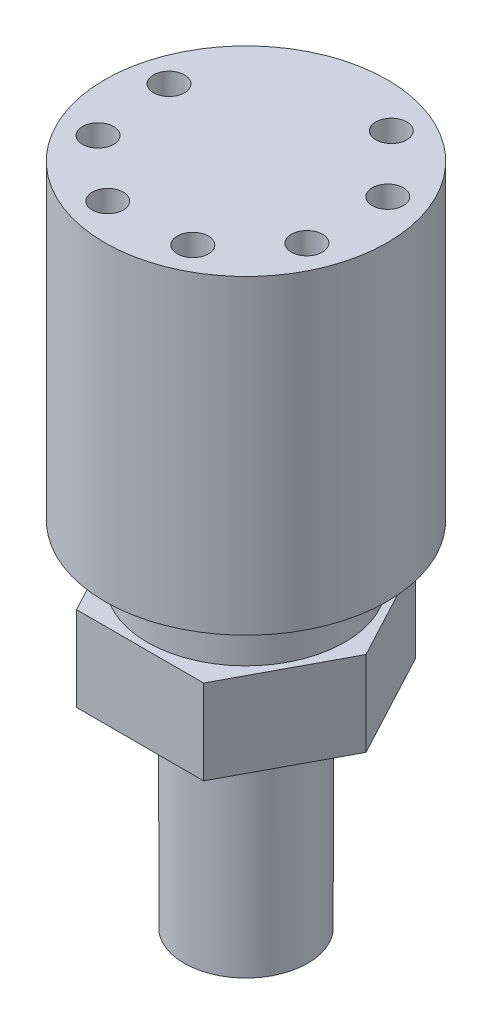
from build123d import *

# Parameters (mm, degrees)
SKETCH1_R           = 8.89
BOSS_EXTRUDE1_DEPTH = 5.08
BOSS_EXTRUDE2_DEPTH = 7.62
SKETCH3_R           = 5.55625
BOSS_EXTRUDE3_DEPTH = 19.05
SKETCH4_R           = 12.7
BOSS_EXTRUDE4_DEPTH = 27.94
SKETCH5_R           = 1.397
CUT_EXTRUDE1_DEPTH  = 20.32


with BuildPart() as part:
    # Sketch1 → Boss-Extrude1 (new body)
    with BuildSketch(Plane(origin=(0, 0, 0), x_dir=(1, 0, 0), z_dir=(0, 1, 0))):
        Circle(SKETCH1_R)
    extrude(amount=BOSS_EXTRUDE1_DEPTH)

    # Sketch2 → Boss-Extrude2 (add)
    with BuildSketch(Plane.XZ):
        Polygon((-5.715, 9.525), (5.715, 9.525), (10.795, 0), (5.715, -9.525), (-5.715, -9.525), (-10.795, 0), align=None)
    extrude(amount=BOSS_EXTRUDE2_DEPTH)

    # Sketch3 → Boss-Extrude3 (add)
    with BuildSketch(Plane(origin=(0, -7.62, 0), x_dir=(-1, 0, 0), z_dir=(0, -1, 0))):
        Circle(SKETCH3_R)
    extrude(amount=BOSS_EXTRUDE3_DEPTH)

    # Sketch4 → Boss-Extrude4 (add)
    with BuildSketch(Plane(origin=(0, 5.08, 0), x_dir=(1, 0, 0), z_dir=(0, 1, 0))):
        Circle(SKETCH4_R)
    extrude(amount=BOSS_EXTRUDE4_DEPTH)

    # Sketch5 → Cut-Extrude1 (cut)
    with BuildSketch(Plane(origin=(0, 33.02, 0), x_dir=(1, 0, 0), z_dir=(0, 1, 0))):
        with Locations((4.171282729, 8.897519777)):
            Circle(SKETCH5_R)
        with Locations((9.139929654, 3.609313469)):
            Circle(SKETCH5_R)
        with Locations((9.125005102, -3.646880814)):
            Circle(SKETCH5_R)
        with Locations((4.134646728, -8.914603425)):
            Circle(SKETCH5_R)
        with Locations((-3.110139008, -9.321614299)):
            Circle(SKETCH5_R)
        with Locations((-8.659113, -4.645989651)):
            Circle(SKETCH5_R)
        with Locations((-9.486682104, 2.562873477)):
            Circle(SKETCH5_R)
    extrude(amount=-CUT_EXTRUDE1_DEPTH, mode=Mode.SUBTRACT)


solid = part.part
